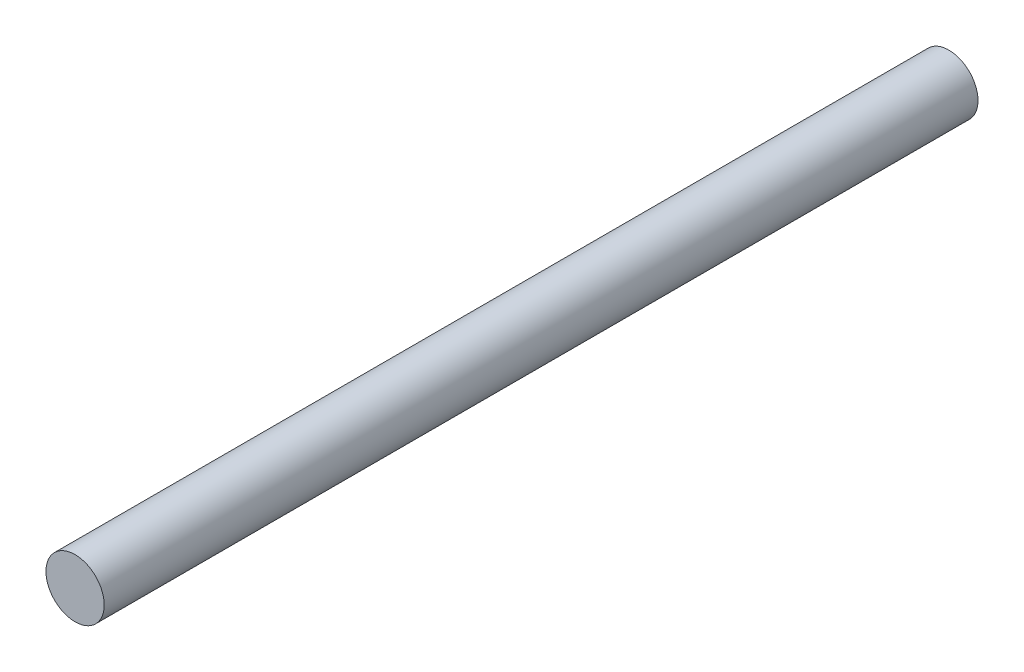
from build123d import *

# Parameters (mm, degrees)
SKETCH1_R           = 6.35
BOSS_EXTRUDE1_DEPTH = 190.5


with BuildPart() as part:
    # Sketch1 → Boss-Extrude1 (new body)
    with BuildSketch(Plane.XY):
        Circle(SKETCH1_R)
    extrude(amount=BOSS_EXTRUDE1_DEPTH)


solid = part.part
